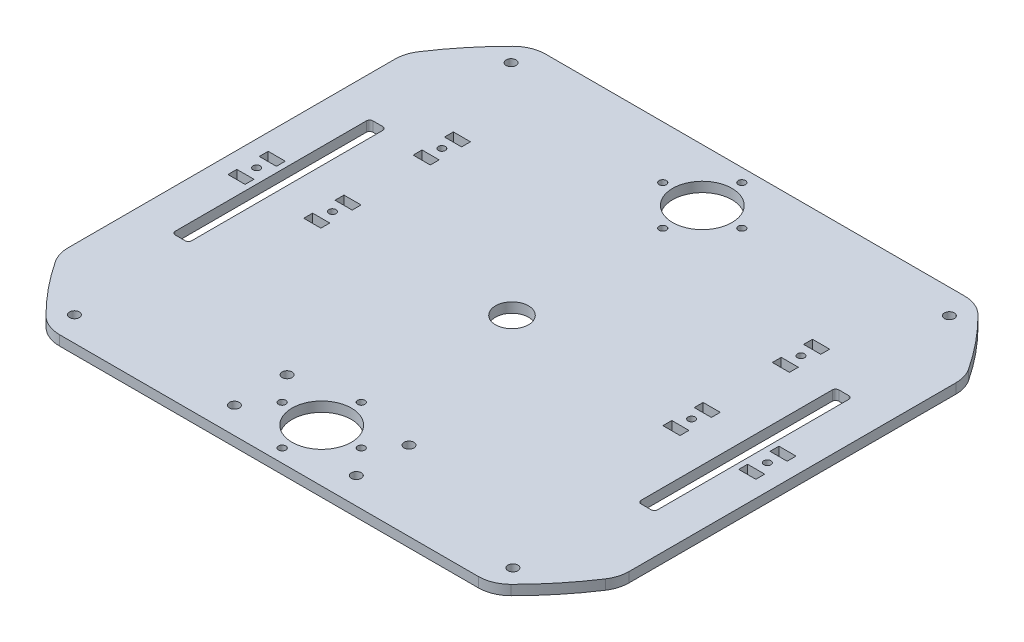
from build123d import *

# Parameters (mm, degrees)
SKETCH1_R                = 100
SKETCH1_R_2              = 5
BOSS_EXTRUDE1_DEPTH      = 3
SKETCH2_W                = 5.2
SKETCH2_H                = 2.7
CUT_EXTRUDE1_DEPTH       = 4
CUT_EXTRUDE2_DEPTH       = 4
SKETCH4_W                = 5
SKETCH4_H                = 60
CUT_EXTRUDE3_DEPTH       = 4
FILLET3_R                = 10
FILLET2_R                = 1
SKETCH5_R                = 1.075
CUT_EXTRUDE4_DEPTH       = 4
SKETCH6_R                = 9
SKETCH6_R_2              = 1.1
CUT_EXTRUDE5_DEPTH       = 4
IR_HOLDER_HOLES_REACH    = 5
IR_HOLDER_HOLES_SKETCH_R = 1.5
PLATFORM_HOLES_REACH     = 5
PLATFORM_HOLES_SKETCH_R  = 1.5


with BuildPart() as part:
    # Sketch1 → Boss-Extrude1 (new body)
    with BuildSketch(Plane(origin=(0, 0, 0), x_dir=(1, 0, 0), z_dir=(0, 1, 0))):
        Circle(SKETCH1_R)
        Circle(SKETCH1_R_2, mode=Mode.SUBTRACT)
    extrude(amount=BOSS_EXTRUDE1_DEPTH)

    # Sketch2 → Cut-Extrude1 (cut, through all)
    with BuildSketch(Plane(origin=(0, 3, 0), x_dir=(1, 0, 0), z_dir=(0, 1, 0))):
        with Locations((-54.5, 37.95)):
            Rectangle(SKETCH2_W, SKETCH2_H)
        with Locations((-54.5, 28.45)):
            Rectangle(SKETCH2_W, SKETCH2_H)
        with Locations((-54.5, 4.75)):
            Rectangle(SKETCH2_W, SKETCH2_H)
        with Locations((-54.5, -4.75)):
            Rectangle(SKETCH2_W, SKETCH2_H)
        with Locations((-77.5, -4.75)):
            Rectangle(SKETCH2_W, SKETCH2_H)
        with Locations((-77.5, 4.75)):
            Rectangle(SKETCH2_W, SKETCH2_H)
        with Locations((54.5, 28.45)):
            Rectangle(SKETCH2_W, SKETCH2_H)
        with Locations((54.5, 37.95)):
            Rectangle(SKETCH2_W, SKETCH2_H)
        with Locations((77.5, 4.75)):
            Rectangle(SKETCH2_W, SKETCH2_H)
        with Locations((77.5, -4.75)):
            Rectangle(SKETCH2_W, SKETCH2_H)
        with Locations((54.5, -4.75)):
            Rectangle(SKETCH2_W, SKETCH2_H)
        with Locations((54.5, 4.75)):
            Rectangle(SKETCH2_W, SKETCH2_H)
    extrude(amount=-CUT_EXTRUDE1_DEPTH, mode=Mode.SUBTRACT)

    # Sketch3 → Cut-Extrude2 (cut, through all)
    with BuildSketch(Plane(origin=(0, 3, 0), x_dir=(1, 0, 0), z_dir=(0, 1, 0))):
        with BuildLine():
            ThreePointArc((67.534713296, 73.75), (0, 100), (-67.534713296, 73.75))
            Line((-67.534713296, 73.75), (67.534713296, 73.75))
        make_face()
        with BuildLine():
            Line((-85.1, -52.516568814), (-85.1, 52.516568814))
            ThreePointArc((-85.1, 52.516568814), (-100, 0), (-85.1, -52.516568814))
        make_face()
        with BuildLine():
            Line((67.534713296, -73.75), (-67.534713296, -73.75))
            ThreePointArc((-67.534713296, -73.75), (0, -100), (67.534713296, -73.75))
        make_face()
        with BuildLine():
            ThreePointArc((100, 0), (96.202910559, 27.294688128), (85.1, 52.516568814))
            Line((85.1, 52.516568814), (85.1, -52.516568814))
            ThreePointArc((85.1, -52.516568814), (96.202910559, -27.294688128), (100, 0))
        make_face()
    extrude(amount=-CUT_EXTRUDE2_DEPTH, mode=Mode.SUBTRACT)

    # Sketch4 → Cut-Extrude3 (cut, through all)
    with BuildSketch(Plane(origin=(0, 3, 0), x_dir=(1, 0, 0), z_dir=(0, 1, 0))):
        with Locations((-70.7, 0)):
            Rectangle(SKETCH4_W, SKETCH4_H)
        with Locations((70.7, 0)):
            Rectangle(SKETCH4_W, SKETCH4_H)
    extrude(amount=-CUT_EXTRUDE3_DEPTH, mode=Mode.SUBTRACT)

    # Fillet3
    fillet3_edges = [part.edges().sort_by_distance(p)[0] for p in [
        (-67.534713296, 1.5, -73.75),
        (67.534713296, 1.5, -73.75),
        (-85.1, 1.5, -52.516568814),
        (-85.1, 1.5, 52.516568814),
        (-67.534713296, 1.5, 73.75),
        (67.534713296, 1.5, 73.75),
        (85.1, 1.5, -52.516568814),
        (85.1, 1.5, 52.516568814),
    ]]
    fillet(fillet3_edges, radius=FILLET3_R)

    # Fillet2
    fillet2_edges = [part.edges().sort_by_distance(p)[0] for p in [
        (-73.2, 1.5, 30),
        (-73.2, 1.5, -30),
        (-68.2, 1.5, -30),
        (-68.2, 1.5, 30),
        (73.2, 1.5, -30),
        (73.2, 1.5, 30),
        (68.2, 1.5, 30),
        (68.2, 1.5, -30),
    ]]
    fillet(fillet2_edges, radius=FILLET2_R)

    # Sketch5 → Cut-Extrude4 (cut, through all)
    with BuildSketch(Plane(origin=(0, 3, 0), x_dir=(1, 0, 0), z_dir=(0, 1, 0))):
        with Locations((-54.5, 33.2)):
            Circle(SKETCH5_R)
        with Locations((-54.5, 0)):
            Circle(SKETCH5_R)
        with Locations((-77.5, 0)):
            Circle(SKETCH5_R)
        with Locations((77.5, 0)):
            Circle(SKETCH5_R)
        with Locations((54.5, 0)):
            Circle(SKETCH5_R)
        with Locations((54.5, 33.2)):
            Circle(SKETCH5_R)
    extrude(amount=-CUT_EXTRUDE4_DEPTH, mode=Mode.SUBTRACT)

    # Sketch6 → Cut-Extrude5 (cut, through all)
    with BuildSketch(Plane(origin=(0, 3, 0), x_dir=(1, 0, 0), z_dir=(0, 1, 0))):
        with Locations((0, 57.75)):
            Circle(SKETCH6_R)
        with Locations((0, 69.75)):
            Circle(SKETCH6_R_2)
        with Locations((12, 57.75)):
            Circle(SKETCH6_R_2)
        with Locations((0, 45.75)):
            Circle(SKETCH6_R_2)
        with Locations((-12, 57.75)):
            Circle(SKETCH6_R_2)
        with Locations((-12, -57.75)):
            Circle(SKETCH6_R_2)
        with Locations((0, -45.75)):
            Circle(SKETCH6_R_2)
        with Locations((12, -57.75)):
            Circle(SKETCH6_R_2)
        with Locations((0, -69.75)):
            Circle(SKETCH6_R_2)
        with Locations((0, -57.75)):
            Circle(SKETCH6_R)
    extrude(amount=-CUT_EXTRUDE5_DEPTH, mode=Mode.SUBTRACT)

    # IR Holder Holes Sketch → IR Holder Holes (cut, up to next)
    with BuildSketch(Plane(origin=(0, 3, 0), x_dir=(1, 0, 0), z_dir=(0, 1, 0)), mode=Mode.PRIVATE) as ir_holder_holes_sk1:
        with Locations((18.5, -65.75)):
            Circle(IR_HOLDER_HOLES_SKETCH_R)
    ir_holder_holes_tool1 = extrude(ir_holder_holes_sk1.sketch, amount=-IR_HOLDER_HOLES_REACH, mode=Mode.PRIVATE) & part.part
    add(ir_holder_holes_tool1.solids().sort_by_distance((18.5, 3, 65.75))[0], mode=Mode.SUBTRACT)
    # IR Holder Holes Sketch → IR Holder Holes (cut, up to next)
    with BuildSketch(Plane(origin=(0, 3, 0), x_dir=(1, 0, 0), z_dir=(0, 1, 0)), mode=Mode.PRIVATE) as ir_holder_holes_sk2:
        with Locations((18.5, -49.75)):
            Circle(IR_HOLDER_HOLES_SKETCH_R)
    ir_holder_holes_tool2 = extrude(ir_holder_holes_sk2.sketch, amount=-IR_HOLDER_HOLES_REACH, mode=Mode.PRIVATE) & part.part
    add(ir_holder_holes_tool2.solids().sort_by_distance((18.5, 3, 49.75))[0], mode=Mode.SUBTRACT)
    # IR Holder Holes Sketch → IR Holder Holes (cut, up to next)
    with BuildSketch(Plane(origin=(0, 3, 0), x_dir=(1, 0, 0), z_dir=(0, 1, 0)), mode=Mode.PRIVATE) as ir_holder_holes_sk3:
        with Locations((-18.5, -65.75)):
            Circle(IR_HOLDER_HOLES_SKETCH_R)
    ir_holder_holes_tool3 = extrude(ir_holder_holes_sk3.sketch, amount=-IR_HOLDER_HOLES_REACH, mode=Mode.PRIVATE) & part.part
    add(ir_holder_holes_tool3.solids().sort_by_distance((-18.5, 3, 65.75))[0], mode=Mode.SUBTRACT)
    # IR Holder Holes Sketch → IR Holder Holes (cut, up to next)
    with BuildSketch(Plane(origin=(0, 3, 0), x_dir=(1, 0, 0), z_dir=(0, 1, 0)), mode=Mode.PRIVATE) as ir_holder_holes_sk4:
        with Locations((-18.5, -49.75)):
            Circle(IR_HOLDER_HOLES_SKETCH_R)
    ir_holder_holes_tool4 = extrude(ir_holder_holes_sk4.sketch, amount=-IR_HOLDER_HOLES_REACH, mode=Mode.PRIVATE) & part.part
    add(ir_holder_holes_tool4.solids().sort_by_distance((-18.5, 3, 49.75))[0], mode=Mode.SUBTRACT)

    # Platform Holes Sketch → Platform Holes (cut, up to next)
    with BuildSketch(Plane(origin=(0, 3, 0), x_dir=(1, 0, 0), z_dir=(0, 1, 0)), mode=Mode.PRIVATE) as platform_holes_sk1:
        with Locations((-66.529028798, 66.25)):
            Circle(PLATFORM_HOLES_SKETCH_R)
    platform_holes_tool1 = extrude(platform_holes_sk1.sketch, amount=-PLATFORM_HOLES_REACH, mode=Mode.PRIVATE) & part.part
    add(platform_holes_tool1.solids().sort_by_distance((-66.529029, 3, -66.25))[0], mode=Mode.SUBTRACT)
    # Platform Holes Sketch → Platform Holes (cut, up to next)
    with BuildSketch(Plane(origin=(0, 3, 0), x_dir=(1, 0, 0), z_dir=(0, 1, 0)), mode=Mode.PRIVATE) as platform_holes_sk2:
        with Locations((66.470971202, 66.25)):
            Circle(PLATFORM_HOLES_SKETCH_R)
    platform_holes_tool2 = extrude(platform_holes_sk2.sketch, amount=-PLATFORM_HOLES_REACH, mode=Mode.PRIVATE) & part.part
    add(platform_holes_tool2.solids().sort_by_distance((66.470971, 3, -66.25))[0], mode=Mode.SUBTRACT)
    # Platform Holes Sketch → Platform Holes (cut, up to next)
    with BuildSketch(Plane(origin=(0, 3, 0), x_dir=(1, 0, 0), z_dir=(0, 1, 0)), mode=Mode.PRIVATE) as platform_holes_sk3:
        with Locations((-66.529028798, -66.25)):
            Circle(PLATFORM_HOLES_SKETCH_R)
    platform_holes_tool3 = extrude(platform_holes_sk3.sketch, amount=-PLATFORM_HOLES_REACH, mode=Mode.PRIVATE) & part.part
    add(platform_holes_tool3.solids().sort_by_distance((-66.529029, 3, 66.25))[0], mode=Mode.SUBTRACT)
    # Platform Holes Sketch → Platform Holes (cut, up to next)
    with BuildSketch(Plane(origin=(0, 3, 0), x_dir=(1, 0, 0), z_dir=(0, 1, 0)), mode=Mode.PRIVATE) as platform_holes_sk4:
        with Locations((66.529028798, -66.25)):
            Circle(PLATFORM_HOLES_SKETCH_R)
    platform_holes_tool4 = extrude(platform_holes_sk4.sketch, amount=-PLATFORM_HOLES_REACH, mode=Mode.PRIVATE) & part.part
    add(platform_holes_tool4.solids().sort_by_distance((66.529029, 3, 66.25))[0], mode=Mode.SUBTRACT)


solid = part.part
